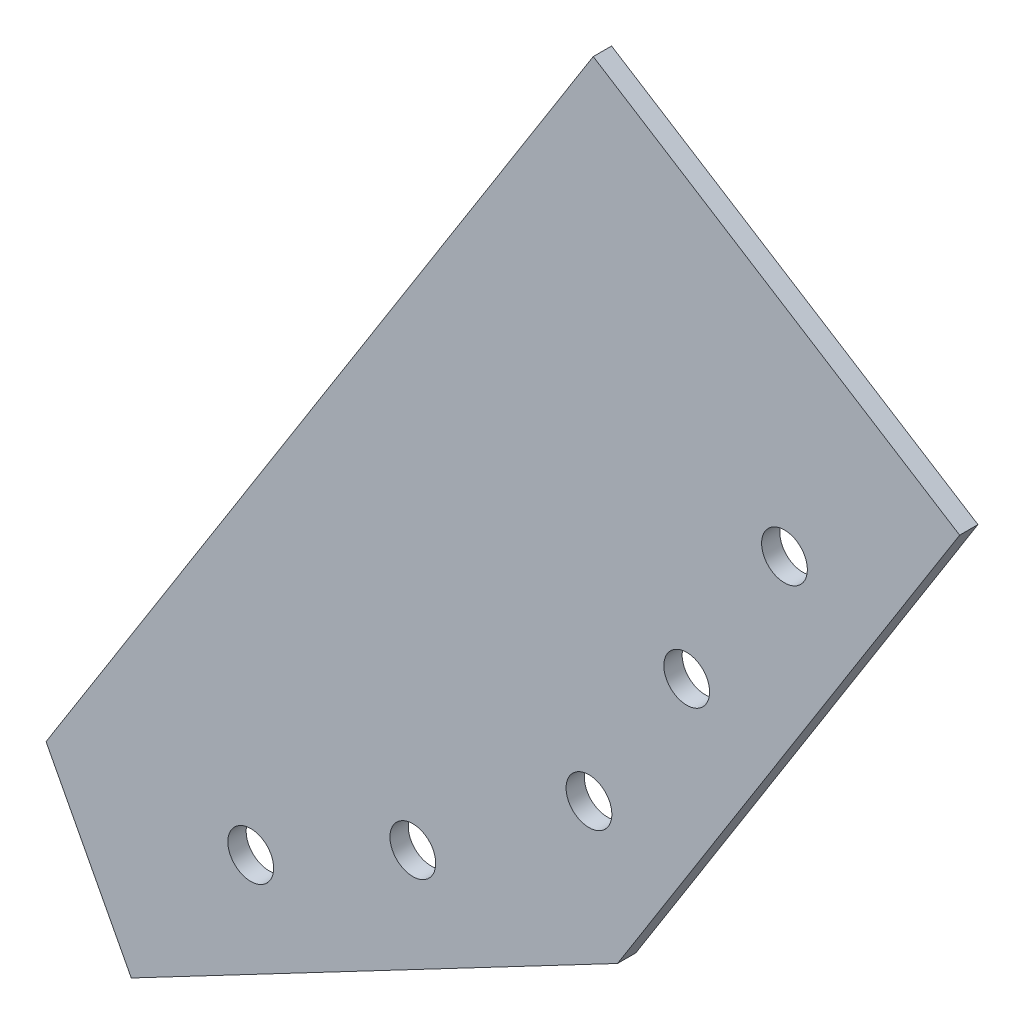
from build123d import *

# Parameters (mm, degrees)
BOSS_EXTRUDE1_DEPTH = 2
SKETCH5_R           = 2.5
CUT_EXTRUDE1_DEPTH  = 2
SKETCH6_R           = 2.5
CUT_EXTRUDE2_DEPTH  = 2
SKETCH7_R           = 2.5
CUT_EXTRUDE3_DEPTH  = 2
SKETCH8_R           = 2.5
CUT_EXTRUDE4_DEPTH  = 40
SKETCH9_R           = 2.5
CUT_EXTRUDE5_DEPTH  = 40


with BuildPart() as part:
    # Sketch2 → Boss-Extrude1 (new body)
    with BuildSketch(Plane.XY):
        Polygon((47.806423209, 40.776843682), (7.791142002, 66.035659063), (-51.971856858, -28.641512814), (-42.663063156, -46.343104828), (10.441712886, -18.416723725), align=None)
    extrude(amount=BOSS_EXTRUDE1_DEPTH)

    # Sketch5 → Cut-Extrude1 (cut)
    with BuildSketch(Plane.XY.offset(2)):
        with Locations((-11.914275979, -18.874721419)):
            Circle(SKETCH5_R)
    extrude(amount=-CUT_EXTRUDE1_DEPTH, mode=Mode.SUBTRACT)

    # Sketch6 → Cut-Extrude2 (cut)
    with BuildSketch(Plane.XY.offset(2)):
        with Locations((-29.615867993, -28.18351512)):
            Circle(SKETCH6_R)
    extrude(amount=-CUT_EXTRUDE2_DEPTH, mode=Mode.SUBTRACT)

    # Sketch7 → Cut-Extrude3 (cut)
    with BuildSketch(Plane.XY.offset(2)):
        with Locations((7.323304731, -4.622684049)):
            Circle(SKETCH7_R)
    extrude(amount=-CUT_EXTRUDE3_DEPTH, mode=Mode.SUBTRACT)

    # Sketch8 → Cut-Extrude4 (cut)
    with BuildSketch(Plane.XY.offset(2)):
        with Locations((17.998936252, 12.289763781)):
            Circle(SKETCH8_R)
    extrude(amount=-CUT_EXTRUDE4_DEPTH, mode=Mode.SUBTRACT)

    # Sketch9 → Cut-Extrude5 (cut)
    with BuildSketch(Plane.XY.offset(2)):
        with Locations((28.674567773, 29.202211612)):
            Circle(SKETCH9_R)
    extrude(amount=-CUT_EXTRUDE5_DEPTH, mode=Mode.SUBTRACT)


solid = part.part
